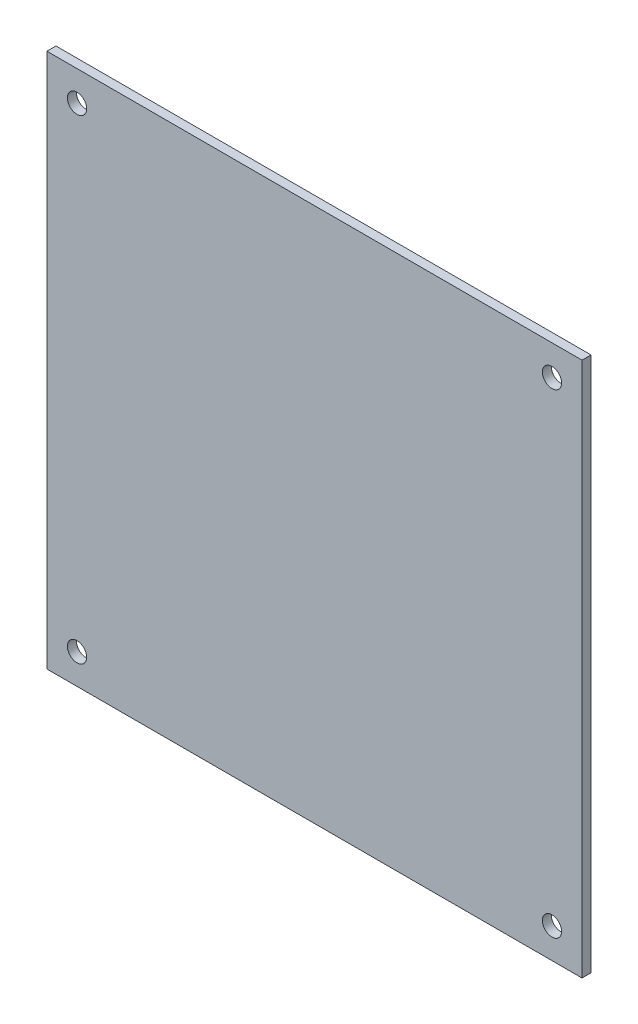
from build123d import *

# Parameters (mm, degrees)
ESQUISSE1_W = 89
ESQUISSE1_H = 89
ESQUISSE1_R = 1.6
MAIN_DEPTH  = 1.5


with BuildPart() as part:
    # Esquisse1 → Main (new body)
    with BuildSketch(Plane.XY):
        Rectangle(ESQUISSE1_W, ESQUISSE1_H)
        with Locations((-39.5, 39.5)):
            Circle(ESQUISSE1_R, mode=Mode.SUBTRACT)
        with Locations((-39.5, -39.5)):
            Circle(ESQUISSE1_R, mode=Mode.SUBTRACT)
        with Locations((39.5, -39.5)):
            Circle(ESQUISSE1_R, mode=Mode.SUBTRACT)
        with Locations((39.5, 39.5)):
            Circle(ESQUISSE1_R, mode=Mode.SUBTRACT)
    extrude(amount=MAIN_DEPTH)


solid = part.part
